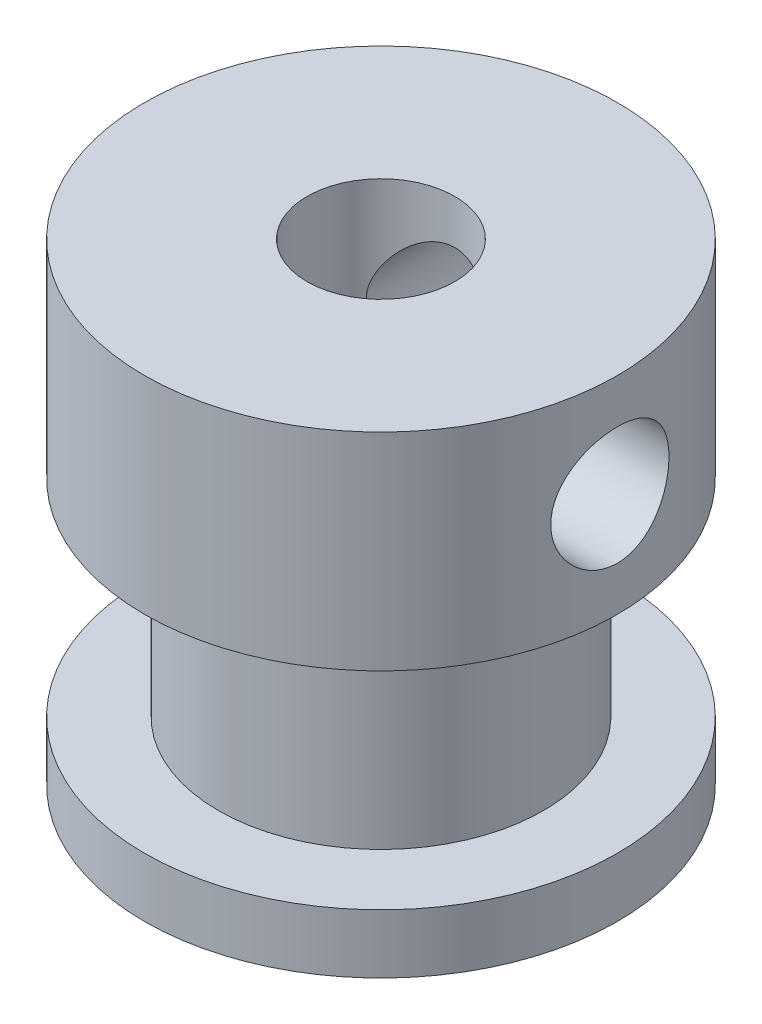
from build123d import *

# Parameters (mm, degrees)
SKETCH1_R           = 8
BOSS_EXTRUDE1_DEPTH = 2
SKETCH2_R           = 5.5
BOSS_EXTRUDE2_DEPTH = 7
SKETCH3_R           = 8
BOSS_EXTRUDE3_DEPTH = 7
SKETCH4_R           = 2.5
CUT_EXTRUDE2_DEPTH  = 17
SKETCH7_R           = 2
CUT_EXTRUDE3_DEPTH  = 9
CIRPATTERN1_COUNT   = 2
CIRPATTERN1_ANGLE   = 90


with BuildPart() as part:
    # Sketch1 → Boss-Extrude1 (new body)
    with BuildSketch(Plane(origin=(0, 0, 0), x_dir=(1, 0, 0), z_dir=(0, 1, 0))):
        Circle(SKETCH1_R)
    extrude(amount=BOSS_EXTRUDE1_DEPTH)

    # Sketch2 → Boss-Extrude2 (add)
    with BuildSketch(Plane(origin=(0, 2, 0), x_dir=(1, 0, 0), z_dir=(0, 1, 0))):
        Circle(SKETCH2_R)
    extrude(amount=BOSS_EXTRUDE2_DEPTH)

    # Sketch3 → Boss-Extrude3 (add)
    with BuildSketch(Plane(origin=(0, 9, 0), x_dir=(1, 0, 0), z_dir=(0, 1, 0))):
        Circle(SKETCH3_R)
    extrude(amount=BOSS_EXTRUDE3_DEPTH)

    # Sketch4 → Cut-Extrude2 (cut, through all)
    with BuildSketch(Plane(origin=(0, 16, 0), x_dir=(1, 0, 0), z_dir=(0, 1, 0))):
        Circle(SKETCH4_R)
    extrude(amount=-CUT_EXTRUDE2_DEPTH, mode=Mode.SUBTRACT)

    # Sketch7 → Cut-Extrude3 (cut, through all)
    with BuildSketch(Plane.XY):
        with Locations((0, 12.5)):
            Circle(SKETCH7_R)
    cut_extrude3 = extrude(amount=-CUT_EXTRUDE3_DEPTH, mode=Mode.SUBTRACT)

    # CirPattern1: Cut-Extrude3 ×2 about axis
    cirpattern1_axis = Axis((0, 16, 0), (0, -1, 0))
    for i in range(1, CIRPATTERN1_COUNT):
        add(cut_extrude3.rotate(cirpattern1_axis, i * CIRPATTERN1_ANGLE / (CIRPATTERN1_COUNT - 1)), mode=Mode.SUBTRACT)


solid = part.part
